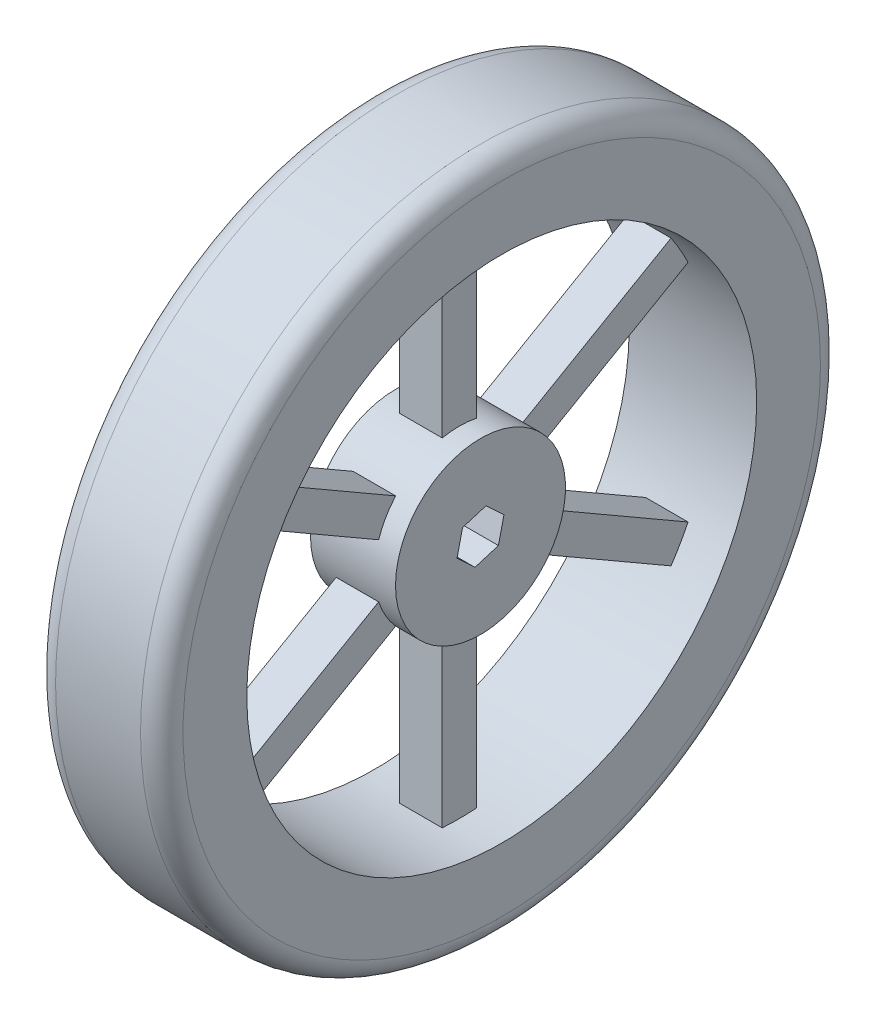
from build123d import *

# Parameters (mm, degrees)
SKETCH1_R                = 101.6
SKETCH1_R_2              = 76.2
BOSS_EXTRUDE1_DEPTH      = 38.1
FILLET1_R                = 6.35
SKETCH2_R                = 25.4
BOSS_EXTRUDE2_DEPTH      = 12.7
BOSS_EXTRUDE2_DEPTH_BACK = 12.7
SKETCH3_W                = 10.17723869
SKETCH3_H                = 65.923797021
BOSS_EXTRUDE3_DEPTH      = 6.35
BOSS_EXTRUDE3_DEPTH_BACK = 6.35


with BuildPart() as part:
    # Sketch1 → Boss-Extrude1 (new body)
    with BuildSketch(Plane(origin=(0, 0, 0), x_dir=(0, 0, -1), z_dir=(1, 0, 0))):
        Circle(SKETCH1_R)
        Circle(SKETCH1_R_2, mode=Mode.SUBTRACT)
    extrude(amount=BOSS_EXTRUDE1_DEPTH)

    # Fillet1
    fillet1_edges = [part.edges().sort_by_distance(p)[0] for p in [
        (0, 0, 101.6),
        (38.1, 0, 101.6),
    ]]
    fillet(fillet1_edges, radius=FILLET1_R)



with BuildPart() as body_2:
    # Sketch2 → Boss-Extrude2 (new body, two sides)
    with BuildSketch(Plane.ZY.offset(-19.05)) as boss_extrude2_sk:
        Circle(SKETCH2_R)
        Polygon((-5.356755209, -5.00684601), (1.657678233, -7.142509098), (7.014433442, -2.135663088), (5.356755209, 5.00684601), (-1.657678233, 7.142509098), (-7.014433442, 2.135663088), align=None, mode=Mode.SUBTRACT)
    extrude(amount=BOSS_EXTRUDE2_DEPTH)
    extrude(boss_extrude2_sk.sketch, amount=-BOSS_EXTRUDE2_DEPTH_BACK)


with BuildPart() as part_1:
    add(part.part)

    add(body_2.part)  # Boss-Extrude3 merges body 2
    # Sketch3 → Boss-Extrude3 (add, two sides)
    with BuildSketch(Plane.ZY.offset(-19.05)) as boss_extrude3_sk:
        Polygon((6.933069311, 9.87864093), (12.021688656, 1.064893684), (69.11337159, 34.026792195), (64.024752245, 42.840539441), align=None)
        with Locations((0, 43.905433126)):
            Rectangle(SKETCH3_W, SKETCH3_H)
        Polygon((12.021688656, -1.064893684), (6.933069311, -9.87864093), (64.024752245, -42.840539441), (69.11337159, -34.026792195), align=None)
        with Locations((0, -43.905433126)):
            Rectangle(SKETCH3_W, SKETCH3_H)
        Polygon((-6.933069311, -9.87864093), (-12.021688656, -1.064893684), (-69.11337159, -34.026792195), (-64.024752245, -42.840539441), align=None)
        Polygon((-12.021688656, 1.064893684), (-6.933069311, 9.87864093), (-64.024752245, 42.840539441), (-69.11337159, 34.026792195), align=None)
    extrude(amount=BOSS_EXTRUDE3_DEPTH)
    extrude(boss_extrude3_sk.sketch, amount=-BOSS_EXTRUDE3_DEPTH_BACK)


solid = part_1.part
